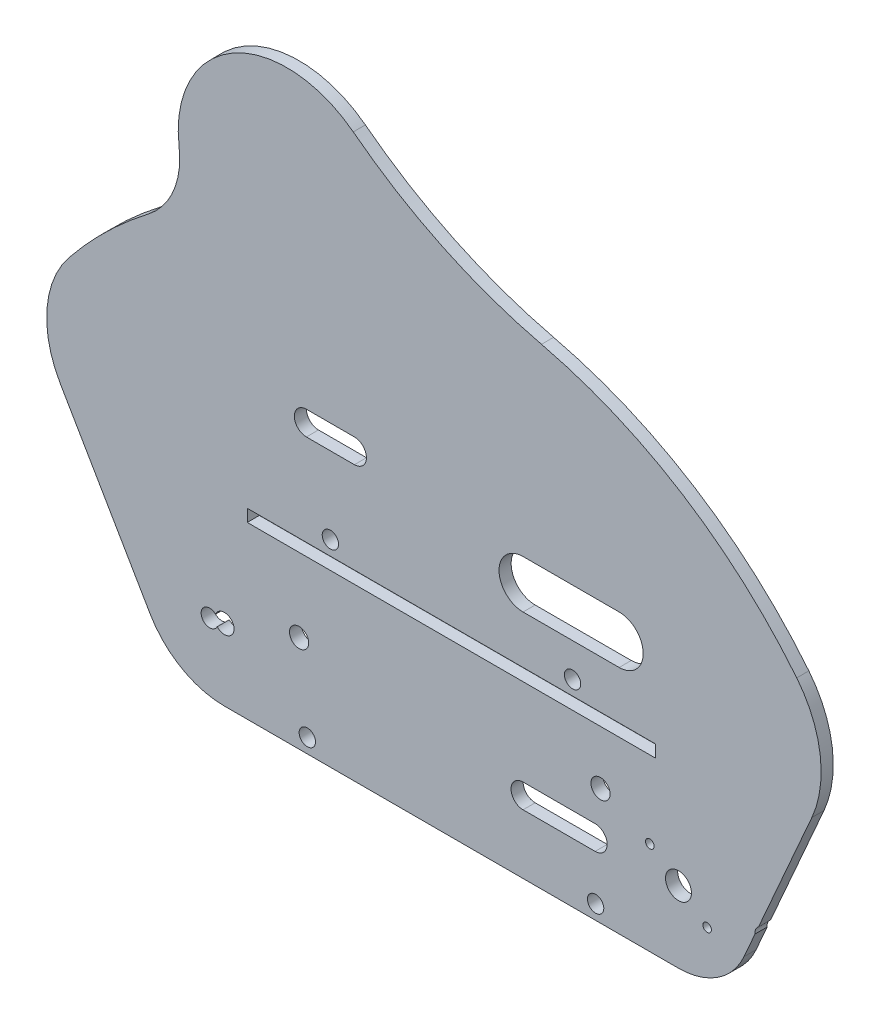
from build123d import *

# Parameters (mm, degrees)
SKETCH1_R           = 3.429
SKETCH1_R_2         = 2.54
BOSS_EXTRUDE1_DEPTH = 3.2004
SKETCH2_R           = 2.159
CUT_EXTRUDE1_DEPTH  = 3.2004
CUT_EXTRUDE8_DEPTH  = 3.2004
SKETCH11_W          = 107.95
SKETCH11_H          = 3.2512
CUT_EXTRUDE9_DEPTH  = 3.2004
SKETCH12_R          = 1.1303
CUT_EXTRUDE11_DEPTH = 3.2004
SKETCH13_R          = 2.2479
CUT_EXTRUDE12_DEPTH = 3.2004
BOSS_EXTRUDE2_DEPTH = 3.2004


with BuildPart() as part:
    # Sketch1 → Boss-Extrude1 (new body)
    with BuildSketch(Plane.XY):
        with BuildLine():
            Line((0, 0), (120.015, 0))
            ThreePointArc((120.015, 0), (130.351788397, 3.075697789), (137.325636158, 11.302152593))
            Line((137.325636158, 11.302152593), (155.257499999, 52.11572))
            ThreePointArc((155.257499999, 52.11572), (157.462147967, 67.664529981), (151.26869294, 82.095991421))
            ThreePointArc((151.26869294, 82.095991421), (55.081013593, 128.103082212), (-41.106665754, 82.095991421))
            ThreePointArc((-41.106665754, 82.095991421), (-46.904819593, 67.459968464), (-43.385473773, 52.11572))
            Line((-43.385473773, 52.11572), (-19.648099871, 11.302152593))
            ThreePointArc((-19.648099871, 11.302152593), (-11.333429333, 3.027112684), (0, 0))
        make_face()
        with Locations((120.015, 18.90776)):
            Circle(SKETCH1_R, mode=Mode.SUBTRACT)
        with Locations((0, 18.90776)):
            Circle(SKETCH1_R_2, mode=Mode.SUBTRACT)
        with Locations((19.734727626, 25.566426992)):
            Circle(SKETCH1_R_2, mode=Mode.SUBTRACT)
        with Locations((99.400822531, 30.809360911)):
            Circle(SKETCH1_R_2, mode=Mode.SUBTRACT)
    extrude(amount=BOSS_EXTRUDE1_DEPTH)

    # Sketch2 → Cut-Extrude1 (cut)
    with BuildSketch(Plane(origin=(0, 0, 0), x_dir=(-1, 0, 0), z_dir=(0, 0, -1))):
        with Locations((-92.0115, 52.115719911)):
            Circle(SKETCH2_R)
        with Locations((-28.0035, 52.115719911)):
            Circle(SKETCH2_R)
        with Locations((-98.1075, 3.81)):
            Circle(SKETCH2_R)
        with Locations((-21.9075, 3.81)):
            Circle(SKETCH2_R)
    extrude(amount=-CUT_EXTRUDE1_DEPTH, mode=Mode.SUBTRACT)

    # Sketch10 → Cut-Extrude8 (cut)
    with BuildSketch(Plane(origin=(0, 0, 0), x_dir=(-1, 0, 0), z_dir=(0, 0, -1))):
        with BuildLine():
            Line((-34.3535, 78.785719911), (-21.6535, 78.785719911))
            ThreePointArc((-21.6535, 78.785719911), (-18.4785, 75.610719911), (-21.6535, 72.435719911))
            Line((-21.6535, 72.435719911), (-34.3535, 72.435719911))
            ThreePointArc((-34.3535, 72.435719911), (-37.5285, 75.610719911), (-34.3535, 78.785719911))
        make_face()
    extrude(amount=-CUT_EXTRUDE8_DEPTH, mode=Mode.SUBTRACT)

    # Sketch11 → Cut-Extrude9 (cut)
    with BuildSketch(Plane(origin=(0, 0, 0), x_dir=(-1, 0, 0), z_dir=(0, 0, -1))):
        with Locations((-60.0075, 46.680119911)):
            Rectangle(SKETCH11_W, SKETCH11_H)
    extrude(amount=-CUT_EXTRUDE9_DEPTH, mode=Mode.SUBTRACT)

    # Sketch12 → Cut-Extrude11 (cut)
    with BuildSketch(Plane.XY.offset(3.2004)):
        with Locations((112.438115095, 24.679799513)):
            Circle(SKETCH12_R)
        with Locations((127.591884905, 13.135720487)):
            Circle(SKETCH12_R)
        with BuildLine():
            Line((78.9305, 73.70572), (104.3305, 73.70572))
            ThreePointArc((104.3305, 73.70572), (110.6805, 67.35572), (104.3305, 61.00572))
            Line((104.3305, 61.00572), (78.9305, 61.00572))
            ThreePointArc((78.9305, 61.00572), (72.5805, 67.35572), (78.9305, 73.70572))
        make_face()
        with BuildLine():
            Line((78.9305, 22.08276), (97.9805, 22.08276))
            ThreePointArc((97.9805, 22.08276), (101.1555, 18.90776), (97.9805, 15.73276))
            Line((97.9805, 15.73276), (78.9305, 15.73276))
            ThreePointArc((78.9305, 15.73276), (75.7555, 18.90776), (78.9305, 22.08276))
        make_face()
    extrude(amount=-CUT_EXTRUDE11_DEPTH, mode=Mode.SUBTRACT)

    # Sketch13 → Cut-Extrude12 (cut)
    with BuildSketch(Plane.XY.offset(3.2004)):
        with Locations((-3.91433865, 18.224067698)):
            Circle(SKETCH13_R)
        with Locations((142.479014632, 18.224067698)):
            Circle(SKETCH13_R)
    extrude(amount=-CUT_EXTRUDE12_DEPTH, mode=Mode.SUBTRACT)

    # Sketch15 → Boss-Extrude2 (add)
    with BuildSketch(Plane(origin=(0, 0, 0), x_dir=(-1, 0, 0), z_dir=(0, 0, -1))):
        with BuildLine():
            Line((-83.804619008, 124.717903233), (20.105573884, 102.592791936))
            ThreePointArc((20.105573884, 102.592791936), (13.448555564, 111.243555983), (11.985080527, 122.060665224))
            ThreePointArc((11.985080527, 122.060665224), (-2.230930753, 150.611793243), (-34.052645192, 148.457639579))
            ThreePointArc((-34.052645192, 148.457639579), (-57.674180086, 133.958784174), (-83.804619008, 124.717903233))
        make_face()
    extrude(amount=-BOSS_EXTRUDE2_DEPTH)


solid = part.part
